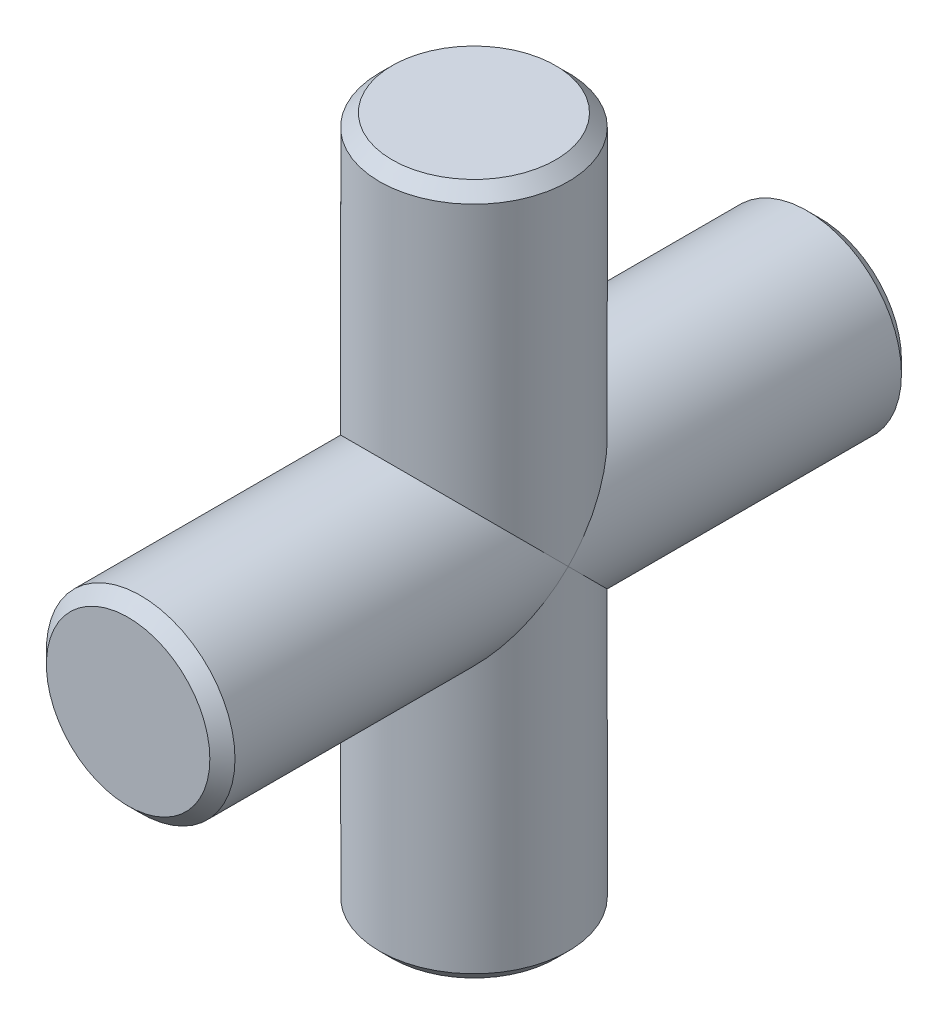
from build123d import *

# Parameters (mm, degrees)
SKETCH_1_R      = 1.5
EXTRUDE_1_DEPTH = 11
SKETCH_2_R      = 1.5
EXTRUDE_2_DEPTH = 5.5
CHAMFER_1_SIZE  = 0.2


with BuildPart() as part:
    # 草图1 → 凸台-拉伸1 (new body)
    with BuildSketch(Plane(origin=(0, 0, 0), x_dir=(1, 0, 0), z_dir=(0, 1, 0))):
        Circle(SKETCH_1_R)
    extrude(amount=EXTRUDE_1_DEPTH)

    # 草图2 → 凸台-拉伸2 (add, symmetric)
    with BuildSketch(Plane.XY):
        with Locations((0, 5.5)):
            Circle(SKETCH_2_R)
    extrude(amount=EXTRUDE_2_DEPTH, both=True)

    # 倒角1
    chamfer_1_edges = [part.edges().sort_by_distance(p)[0] for p in [
        (-1.5, 5.5, 5.5),
        (-1.5, 0, 0),
        (-1.5, 5.5, -5.5),
        (-1.5, 11, 0),
    ]]
    chamfer(chamfer_1_edges, length=CHAMFER_1_SIZE)


solid = part.part
